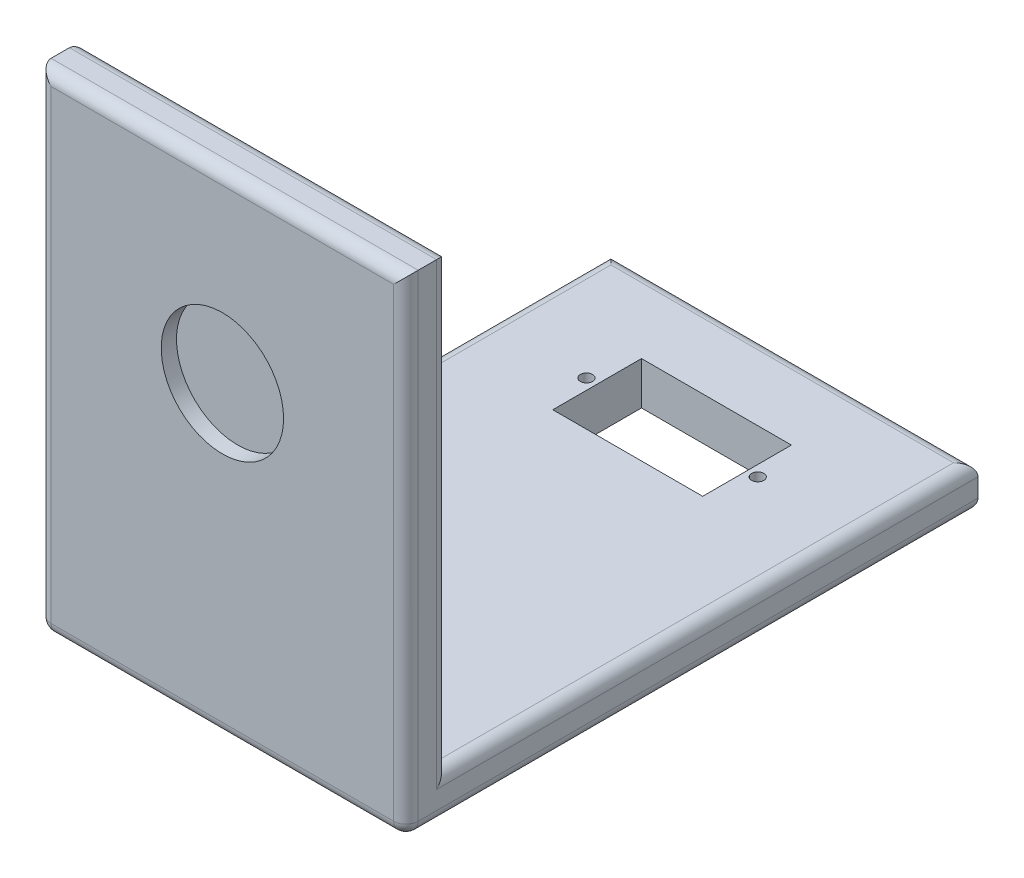
from build123d import *

# Parameters (mm, degrees)
BASE_DEPTH              = 3.5
BASE_DEPTH_BACK         = 3.5
CROQUIS1_W              = 60
CROQUIS1_H              = 90
AGUJERO_SERVO_REACH     = 56.534
CROQUIS2_R              = 1
CROQUIS2_W              = 24.5
CROQUIS2_H              = 14.5
PARED_DEPTH             = 3.5
PARED_DEPTH_BACK        = 3.5
CROQUIS3_W              = 60
CROQUIS3_H              = 80
REDONDEO2_R             = 2
CROQUIS4_R              = 10
RECORTENUEVOSERVO_DEPTH = 2.5


with BuildPart() as part:
    # Croquis1 → Base (new, two sides: drawn at the far end of the back side and taken through both)
    with BuildSketch(Plane(origin=(0, 0, 0), x_dir=(1, 0, 0), z_dir=(0, 1, 0)).offset(-BASE_DEPTH_BACK)):
        Rectangle(CROQUIS1_W, CROQUIS1_H)
    extrude(amount=BASE_DEPTH + BASE_DEPTH_BACK)

    # Croquis2 → Agujero Servo (cut, up to next)
    with BuildSketch(Plane(origin=(0, 3.5, 0), x_dir=(1, 0, 0), z_dir=(0, 1, 0)), mode=Mode.PRIVATE) as agujero_servo_sk1:
        with Locations((-14, 25)):
            Circle(CROQUIS2_R)
    agujero_servo_tool1 = extrude(agujero_servo_sk1.sketch, amount=-AGUJERO_SERVO_REACH, mode=Mode.PRIVATE) & part.part
    # Croquis2 → Agujero Servo (cut, up to next)
    with BuildSketch(Plane(origin=(0, 3.5, 0), x_dir=(1, 0, 0), z_dir=(0, 1, 0)), mode=Mode.PRIVATE) as agujero_servo_sk2:
        with Locations((14, 25)):
            Circle(CROQUIS2_R)
    agujero_servo_tool2 = extrude(agujero_servo_sk2.sketch, amount=-AGUJERO_SERVO_REACH, mode=Mode.PRIVATE) & part.part
    # Croquis2 → Agujero Servo (cut, up to next)
    with BuildSketch(Plane(origin=(0, 3.5, 0), x_dir=(1, 0, 0), z_dir=(0, 1, 0)), mode=Mode.PRIVATE) as agujero_servo_sk3:
        with Locations((0, 25)):
            Rectangle(CROQUIS2_W, CROQUIS2_H)
    agujero_servo_tool3 = extrude(agujero_servo_sk3.sketch, amount=-AGUJERO_SERVO_REACH, mode=Mode.PRIVATE) & part.part
    add(agujero_servo_tool1.solids().sort_by_distance((-14, 3.5, -25))[0], mode=Mode.SUBTRACT)
    add(agujero_servo_tool2.solids().sort_by_distance((14, 3.5, -25))[0], mode=Mode.SUBTRACT)
    add(agujero_servo_tool3.solids().sort_by_distance((0, 3.5, -25))[0], mode=Mode.SUBTRACT)

    # Croquis3 → Pared (add, two sides: drawn at the far end of the back side and taken through both)
    with BuildSketch(Plane.XY.offset(45).offset(-PARED_DEPTH_BACK)):
        with Locations((0, 36.5)):
            Rectangle(CROQUIS3_W, CROQUIS3_H)
    extrude(amount=PARED_DEPTH + PARED_DEPTH_BACK)

    # Redondeo2
    redondeo2_edges = [part.edges().sort_by_distance(p)[0] for p in [
        (0, 76.5, 48.5),
        (30, 36.5, 48.5),
        (0, -3.5, 48.5),
        (-30, 36.5, 48.5),
        (-30, 40, 41.5),
        (30, 40, 41.5),
        (0, 76.5, 41.5),
        (30, -3.5, 1.75),
        (30, 3.5, -1.75),
        (0, -3.5, -45),
        (0, 3.5, -45),
        (-30, -3.5, 1.75),
        (-30, 3.5, -1.75),
    ]]
    fillet(redondeo2_edges, radius=REDONDEO2_R)

    # Croquis4 → RecorteNuevoServo (cut)
    with BuildSketch(Plane.XY.offset(48.5)):
        with Locations((0, 46.5)):
            Circle(CROQUIS4_R)
    extrude(amount=-RECORTENUEVOSERVO_DEPTH, mode=Mode.SUBTRACT)


solid = part.part
